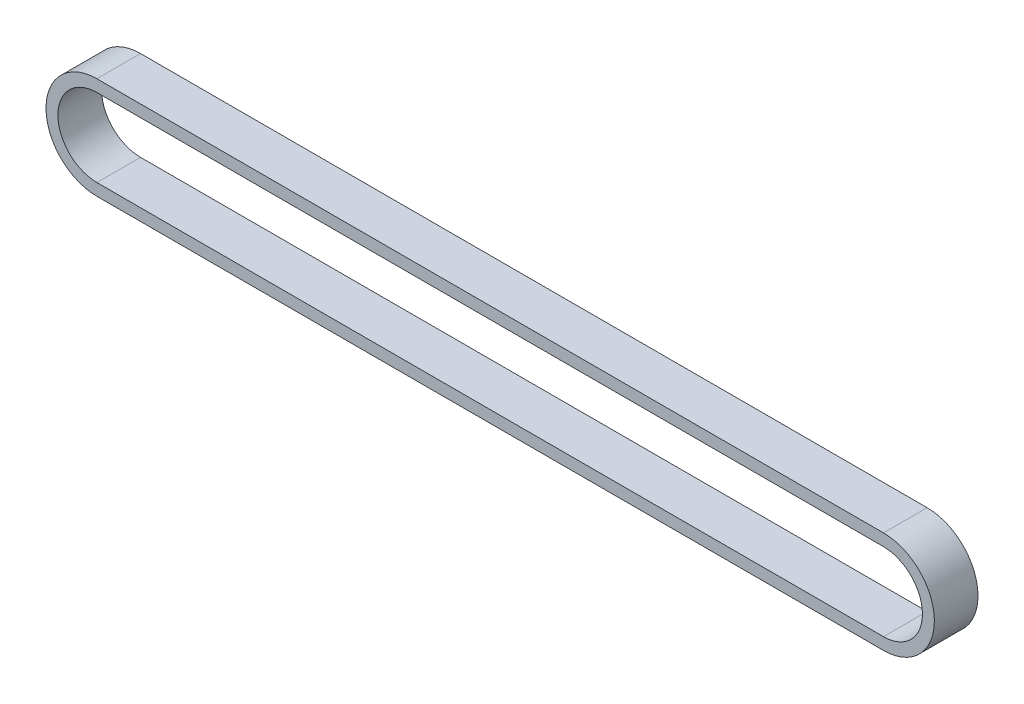
from build123d import *

# Parameters (mm, degrees)
BOSS_EXTRUDE1_DEPTH = 3


with BuildPart() as part:
    # Sketch1 → Boss-Extrude1 (new body, symmetric)
    with BuildSketch(Plane.XY):
        with BuildLine():
            Line((0, 7), (108.161063377, 7))
            ThreePointArc((108.161063377, 7), (115.161063377, 0), (108.161063377, -7))
            Line((108.161063377, -7), (0, -7))
            ThreePointArc((0, -7), (-7, 0), (0, 7))
        make_face()
        with BuildLine():
            Line((0, 5.36), (108.161063377, 5.36))
            ThreePointArc((108.161063377, 5.36), (113.521063377, 0), (108.161063377, -5.36))
            Line((108.161063377, -5.36), (0, -5.36))
            ThreePointArc((0, -5.36), (-5.36, 0), (0, 5.36))
        make_face(mode=Mode.SUBTRACT)
    extrude(amount=BOSS_EXTRUDE1_DEPTH, both=True)


solid = part.part
